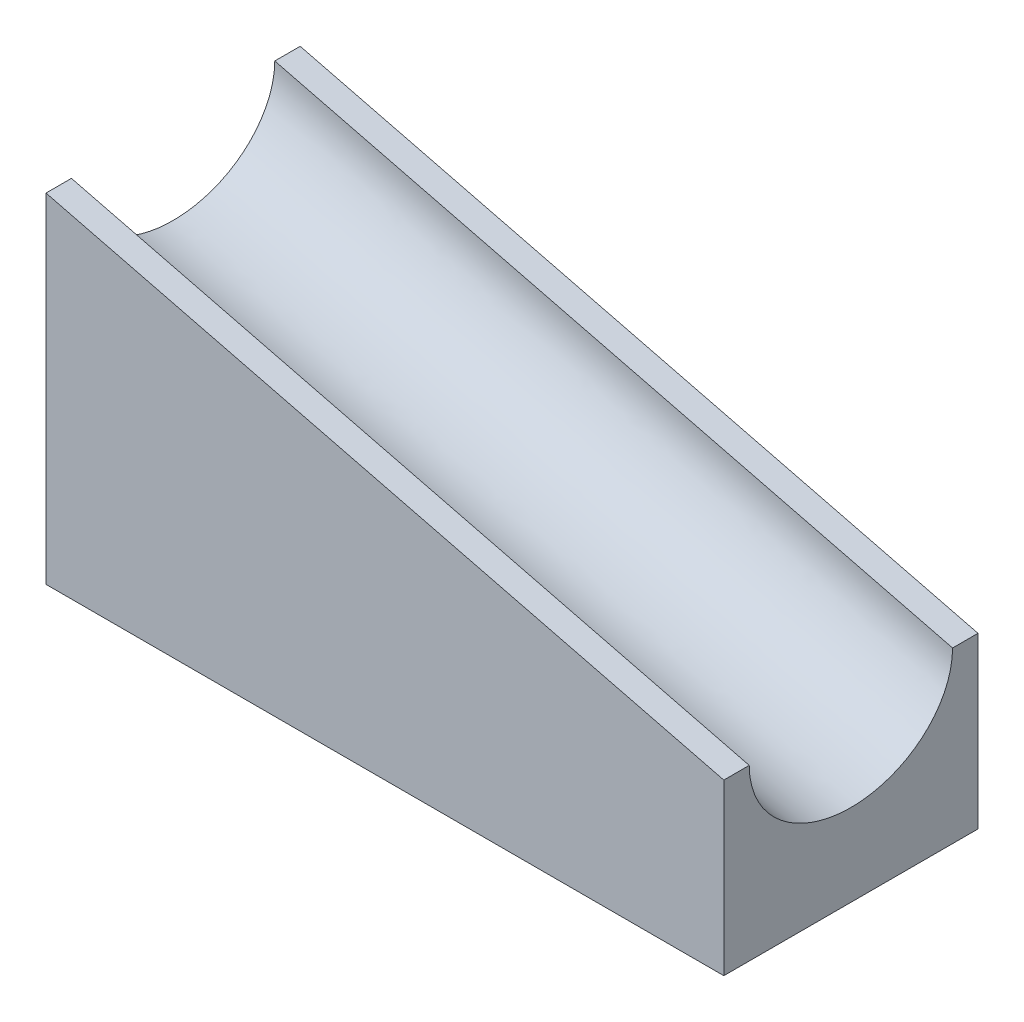
from build123d import *

# Parameters (mm, degrees)
BOSS_EXTRUDE1_DEPTH = 19.05
SKETCH3_RX          = 7.62
SKETCH3_RY          = 6.35
CUT_EXTRUDE1_DEPTH  = 56.443643883


with BuildPart() as part:
    # Sketch1 → Boss-Extrude1 (new body)
    with BuildSketch(Plane.XY):
        Polygon((-25.4, 12.7), (-25.4, -12.7), (25.4, -12.7), (25.4, 0), align=None)
    extrude(amount=BOSS_EXTRUDE1_DEPTH)

    # Sketch3 → Cut-Extrude1 (cut, through all)
    with BuildSketch(Plane(origin=(-26.894117647, 6.723529412, 0), x_dir=(0, 0, -1), z_dir=(-0.9701425, 0.242535625, 0))):
        with Locations(Location((-9.525, -6.160404876), (0, 0, 0))):
            Ellipse(SKETCH3_RX, SKETCH3_RY)
    extrude(amount=-CUT_EXTRUDE1_DEPTH, mode=Mode.SUBTRACT)


solid = part.part
